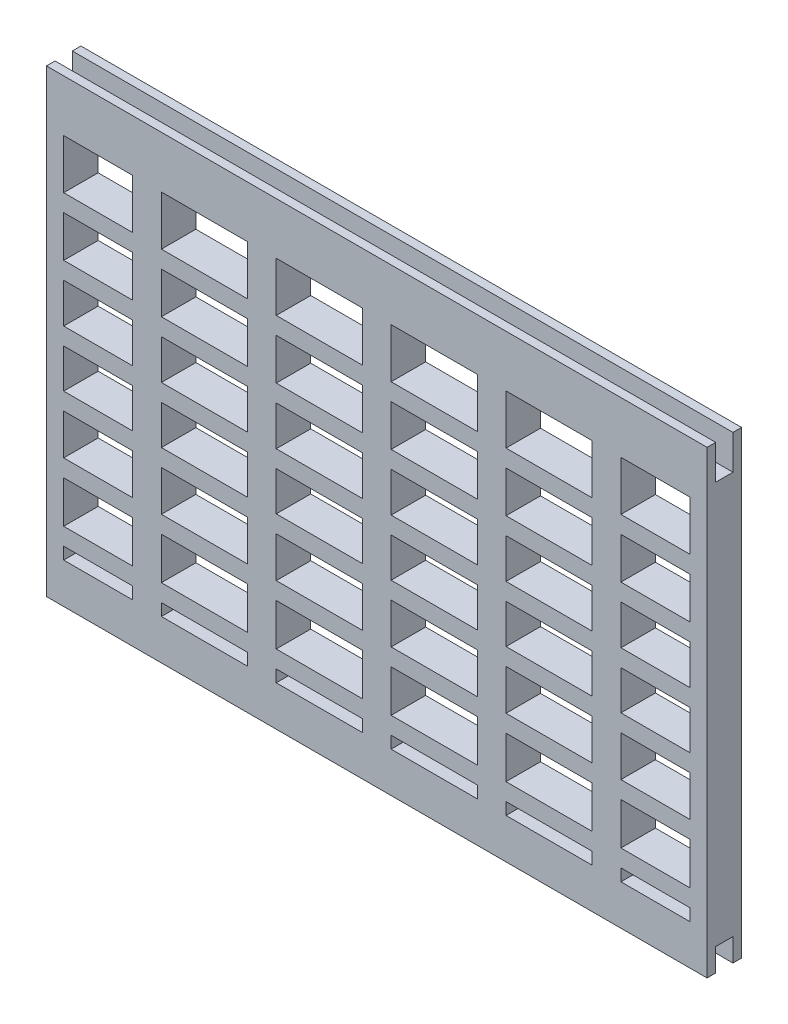
from build123d import *

# Parameters (mm, degrees)
ESBO_O1_W                  = 115
ESBO_O1_H                  = 80
ESBO_O1_W_2                = 12.008486519
ESBO_O1_H_2                = 2.098343741
ESBO_O1_W_3                = 14.991513481
ESBO_O1_H_3                = 7.310170624
ESBO_O1_W_4                = 15
ESBO_O1_H_4                = 7.061661657
ESBO_O1_H_5                = 6.81374745
ESBO_O1_W_5                = 14.997964619
ESBO_O1_W_6                = 12
ESBO_O1_H_6                = 6.901670661
ESBO_O1_H_7                = 7.197630057
ESBO_O1_H_8                = 8.61677581
RESSALTO_EXTRUS_O1_DEPTH   = 6
ESBO_O2_W                  = 3
ESBO_O2_H                  = 3.99391125
ESBO_O2_H_2                = 6.002879156
CORTE_EXTRUS_O1_DEPTH      = 58.5
CORTE_EXTRUS_O1_DEPTH_BACK = 58.5


with BuildPart() as part:
    # Esboço1 → Ressalto-extrusão1 (new body)
    with BuildSketch(Plane.XY):
        with Locations((0, -0.783923472)):
            Rectangle(ESBO_O1_W, ESBO_O1_H)
        with Locations((-48.49575674, -32.734751602)):
            Rectangle(ESBO_O1_W_2, ESBO_O1_H_2, mode=Mode.SUBTRACT)
        with Locations((-29.995756741, -32.734751602)):
            Rectangle(ESBO_O1_W_3, ESBO_O1_H_2, mode=Mode.SUBTRACT)
        with Locations((-48.49575674, -25.030494419)):
            Rectangle(ESBO_O1_W_2, ESBO_O1_H_3, mode=Mode.SUBTRACT)
        with Locations((-29.995756741, -25.030494419)):
            Rectangle(ESBO_O1_W_3, ESBO_O1_H_3, mode=Mode.SUBTRACT)
        with Locations((-10, -32.734751602)):
            Rectangle(ESBO_O1_W_4, ESBO_O1_H_2, mode=Mode.SUBTRACT)
        with Locations((-10, -25.030494419)):
            Rectangle(ESBO_O1_W_4, ESBO_O1_H_3, mode=Mode.SUBTRACT)
        with Locations((-48.49575674, -14.844578279)):
            Rectangle(ESBO_O1_W_2, ESBO_O1_H_4, mode=Mode.SUBTRACT)
        with Locations((-29.995756741, -14.844578279)):
            Rectangle(ESBO_O1_W_3, ESBO_O1_H_4, mode=Mode.SUBTRACT)
        with Locations((-48.49575674, -4.906873725)):
            Rectangle(ESBO_O1_W_2, ESBO_O1_H_5, mode=Mode.SUBTRACT)
        with Locations((-29.995756741, -4.906873725)):
            Rectangle(ESBO_O1_W_3, ESBO_O1_H_5, mode=Mode.SUBTRACT)
        with Locations((-10, -14.844578279)):
            Rectangle(ESBO_O1_W_4, ESBO_O1_H_4, mode=Mode.SUBTRACT)
        with Locations((-10, -4.906873725)):
            Rectangle(ESBO_O1_W_4, ESBO_O1_H_5, mode=Mode.SUBTRACT)
        with Locations((9.99898231, -32.734751602)):
            Rectangle(ESBO_O1_W_5, ESBO_O1_H_2, mode=Mode.SUBTRACT)
        with Locations((9.99898231, -25.030494419)):
            Rectangle(ESBO_O1_W_5, ESBO_O1_H_3, mode=Mode.SUBTRACT)
        with Locations((30.00101769, -32.734751602)):
            Rectangle(ESBO_O1_W_5, ESBO_O1_H_2, mode=Mode.SUBTRACT)
        with Locations((48.5, -32.734751602)):
            Rectangle(ESBO_O1_W_6, ESBO_O1_H_2, mode=Mode.SUBTRACT)
        with Locations((30.00101769, -25.030494419)):
            Rectangle(ESBO_O1_W_5, ESBO_O1_H_3, mode=Mode.SUBTRACT)
        with Locations((48.5, -25.030494419)):
            Rectangle(ESBO_O1_W_6, ESBO_O1_H_3, mode=Mode.SUBTRACT)
        with Locations((9.99898231, -14.844578279)):
            Rectangle(ESBO_O1_W_5, ESBO_O1_H_4, mode=Mode.SUBTRACT)
        with Locations((9.99898231, -4.906873725)):
            Rectangle(ESBO_O1_W_5, ESBO_O1_H_5, mode=Mode.SUBTRACT)
        with Locations((30.00101769, -14.844578279)):
            Rectangle(ESBO_O1_W_5, ESBO_O1_H_4, mode=Mode.SUBTRACT)
        with Locations((48.5, -14.844578279)):
            Rectangle(ESBO_O1_W_6, ESBO_O1_H_4, mode=Mode.SUBTRACT)
        with Locations((30.00101769, -4.906873725)):
            Rectangle(ESBO_O1_W_5, ESBO_O1_H_5, mode=Mode.SUBTRACT)
        with Locations((48.5, -4.906873725)):
            Rectangle(ESBO_O1_W_6, ESBO_O1_H_5, mode=Mode.SUBTRACT)
        with Locations((-48.49575674, 4.950835331)):
            Rectangle(ESBO_O1_W_2, ESBO_O1_H_6, mode=Mode.SUBTRACT)
        with Locations((-29.995756741, 4.950835331)):
            Rectangle(ESBO_O1_W_3, ESBO_O1_H_6, mode=Mode.SUBTRACT)
        with Locations((-10, 4.950835331)):
            Rectangle(ESBO_O1_W_4, ESBO_O1_H_6, mode=Mode.SUBTRACT)
        with Locations((-48.49575674, 15.00048569)):
            Rectangle(ESBO_O1_W_2, ESBO_O1_H_7, mode=Mode.SUBTRACT)
        with Locations((-29.995756741, 15.00048569)):
            Rectangle(ESBO_O1_W_3, ESBO_O1_H_7, mode=Mode.SUBTRACT)
        with Locations((-48.49575674, 25.907688623)):
            Rectangle(ESBO_O1_W_2, ESBO_O1_H_8, mode=Mode.SUBTRACT)
        with Locations((-29.995756741, 25.907688623)):
            Rectangle(ESBO_O1_W_3, ESBO_O1_H_8, mode=Mode.SUBTRACT)
        with Locations((-10, 15.00048569)):
            Rectangle(ESBO_O1_W_4, ESBO_O1_H_7, mode=Mode.SUBTRACT)
        with Locations((-10, 25.907688623)):
            Rectangle(ESBO_O1_W_4, ESBO_O1_H_8, mode=Mode.SUBTRACT)
        with Locations((9.99898231, 4.950835331)):
            Rectangle(ESBO_O1_W_5, ESBO_O1_H_6, mode=Mode.SUBTRACT)
        with Locations((30.00101769, 4.950835331)):
            Rectangle(ESBO_O1_W_5, ESBO_O1_H_6, mode=Mode.SUBTRACT)
        with Locations((48.5, 4.950835331)):
            Rectangle(ESBO_O1_W_6, ESBO_O1_H_6, mode=Mode.SUBTRACT)
        with Locations((9.99898231, 15.00048569)):
            Rectangle(ESBO_O1_W_5, ESBO_O1_H_7, mode=Mode.SUBTRACT)
        with Locations((9.99898231, 25.907688623)):
            Rectangle(ESBO_O1_W_5, ESBO_O1_H_8, mode=Mode.SUBTRACT)
        with Locations((30.00101769, 15.00048569)):
            Rectangle(ESBO_O1_W_5, ESBO_O1_H_7, mode=Mode.SUBTRACT)
        with Locations((48.5, 15.00048569)):
            Rectangle(ESBO_O1_W_6, ESBO_O1_H_7, mode=Mode.SUBTRACT)
        with Locations((30.00101769, 25.907688623)):
            Rectangle(ESBO_O1_W_5, ESBO_O1_H_8, mode=Mode.SUBTRACT)
        with Locations((48.5, 25.907688623)):
            Rectangle(ESBO_O1_W_6, ESBO_O1_H_8, mode=Mode.SUBTRACT)
    extrude(amount=RESSALTO_EXTRUS_O1_DEPTH)

    # Esboço2 → Corte-extrusão1 (cut, two sides)
    with BuildSketch(Plane(origin=(0, 0, 0), x_dir=(0, 0, -1), z_dir=(1, 0, 0))) as corte_extrus_o1_sk:
        with Locations((-3, -38.786967847)):
            Rectangle(ESBO_O2_W, ESBO_O2_H)
        with Locations((-3, 36.21463695)):
            Rectangle(ESBO_O2_W, ESBO_O2_H_2)
    extrude(amount=CORTE_EXTRUS_O1_DEPTH, mode=Mode.SUBTRACT)
    extrude(corte_extrus_o1_sk.sketch, amount=-CORTE_EXTRUS_O1_DEPTH_BACK, mode=Mode.SUBTRACT)


solid = part.part
